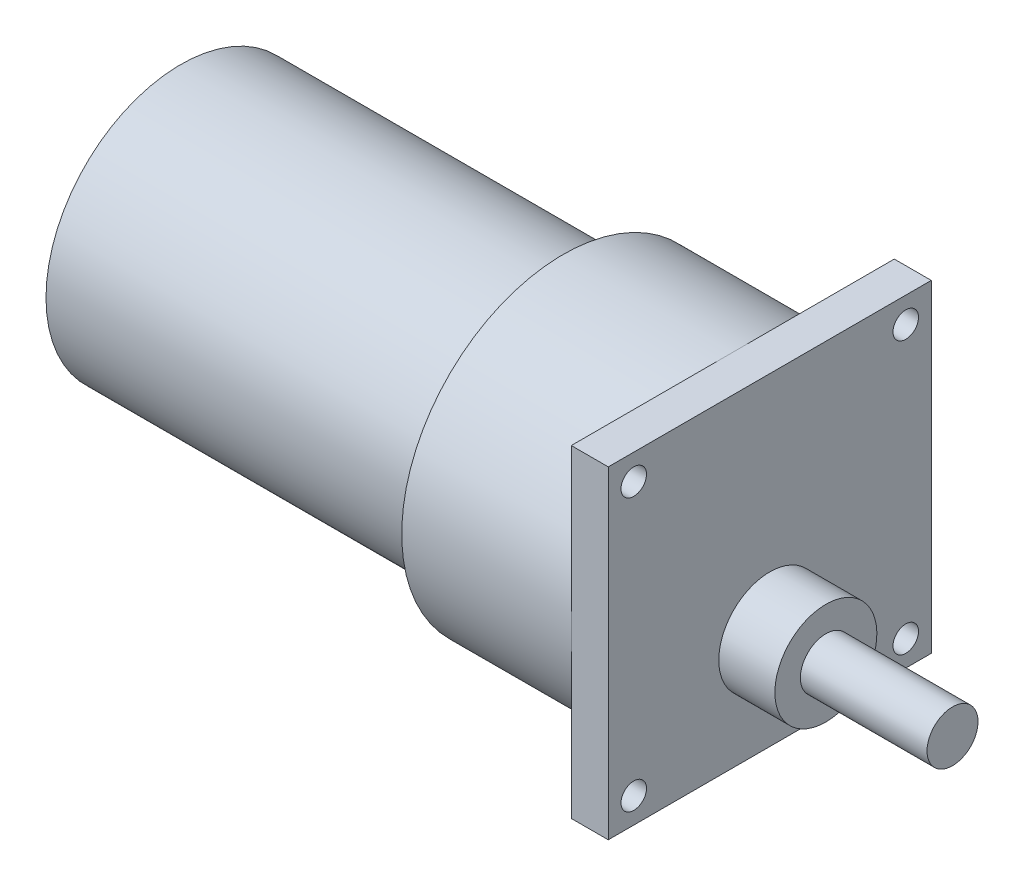
from build123d import *

# Parameters (mm, degrees)
BOSS_EXTRUDE1_DEPTH   = 24.3
BOSS_EXTRUDE2_DEPTH   = 4.35
SKETCH2_R             = 15.85
BOSS_EXTRUDE3_DEPTH   = 45
CORTE_EXTRUS_O1_REACH = 76.327
ESBO_O3_R             = 1.5


with BuildPart() as part:
    # Sketch1 → Boss-Extrude1 (new body)
    with BuildSketch(Plane(origin=(0, 0, 0), x_dir=(0, 0, -1), z_dir=(1, 0, 0))):
        with BuildLine():
            ThreePointArc((19, 0), (13.435028855, 13.43502883), (3.5e-08, 19))
            ThreePointArc((3.5e-08, 19), (-13.435028834, 13.435028851), (-19, -9e-09))
            ThreePointArc((-19, -9e-09), (-13.435028829, -13.435028856), (2.8e-08, -19))
            ThreePointArc((2.8e-08, -19), (13.435028852, -13.435028833), (19, 0))
        make_face()
    extrude(amount=-BOSS_EXTRUDE1_DEPTH)

    # Sketch1_3 → Boss-Extrude2 (add)
    with BuildSketch(Plane(origin=(0, 0, 0), x_dir=(0, 0, -1), z_dir=(1, 0, 0))):
        with BuildLine():
            Line((3.5e-08, 19), (-19, 19))
            Line((-19, 19), (-19, -9e-09))
            ThreePointArc((-19, -9e-09), (-13.435028834, 13.435028851), (3.5e-08, 19))
        make_face()
        with BuildLine():
            Line((19, 19), (3.5e-08, 19))
            ThreePointArc((3.5e-08, 19), (13.435028855, 13.43502883), (19, 0))
            Line((19, 0), (19, 19))
        make_face()
        with BuildLine():
            ThreePointArc((2.8e-08, -19), (-13.435028829, -13.435028856), (-19, -9e-09))
            Line((-19, -9e-09), (-19, -19))
            Line((-19, -19), (2.8e-08, -19))
        make_face()
        with BuildLine():
            Line((19, -19), (19, 0))
            ThreePointArc((19, 0), (13.435028852, -13.435028833), (2.8e-08, -19))
            Line((2.8e-08, -19), (19, -19))
        make_face()
    extrude(amount=-BOSS_EXTRUDE2_DEPTH)

    # Sketch2 → Boss-Extrude3 (add)
    with BuildSketch(Plane.ZY.offset(24.3)):
        Circle(SKETCH2_R)
    extrude(amount=BOSS_EXTRUDE3_DEPTH)

    # Esboço2 → Revolução1 (revolve)
    with BuildSketch(Plane.XY):
        Polygon((0, -1.2), (6.6, -1.2), (6.6, -4.2), (21.5, -4.2), (21.5, -7.2), (0, -7.2), align=None)
    revolve(axis=Axis((0, -7.2, 0), (1, 0, 0)))

    # Esboço3 → Corte-extrusão1 (cut, up to next)
    with BuildSketch(Plane(origin=(0, 0, 0), x_dir=(0, 0, -1), z_dir=(1, 0, 0)), mode=Mode.PRIVATE) as corte_extrus_o1_sk1:
        with Locations((-16, 16)):
            Circle(ESBO_O3_R)
    corte_extrus_o1_tool1 = extrude(corte_extrus_o1_sk1.sketch, amount=-CORTE_EXTRUS_O1_REACH, mode=Mode.PRIVATE) & part.part
    # Esboço3 → Corte-extrusão1 (cut, up to next)
    with BuildSketch(Plane(origin=(0, 0, 0), x_dir=(0, 0, -1), z_dir=(1, 0, 0)), mode=Mode.PRIVATE) as corte_extrus_o1_sk2:
        with Locations((16, 16)):
            Circle(ESBO_O3_R)
    corte_extrus_o1_tool2 = extrude(corte_extrus_o1_sk2.sketch, amount=-CORTE_EXTRUS_O1_REACH, mode=Mode.PRIVATE) & part.part
    # Esboço3 → Corte-extrusão1 (cut, up to next)
    with BuildSketch(Plane(origin=(0, 0, 0), x_dir=(0, 0, -1), z_dir=(1, 0, 0)), mode=Mode.PRIVATE) as corte_extrus_o1_sk3:
        with Locations((16, -16)):
            Circle(ESBO_O3_R)
    corte_extrus_o1_tool3 = extrude(corte_extrus_o1_sk3.sketch, amount=-CORTE_EXTRUS_O1_REACH, mode=Mode.PRIVATE) & part.part
    # Esboço3 → Corte-extrusão1 (cut, up to next)
    with BuildSketch(Plane(origin=(0, 0, 0), x_dir=(0, 0, -1), z_dir=(1, 0, 0)), mode=Mode.PRIVATE) as corte_extrus_o1_sk4:
        with Locations((-16, -16)):
            Circle(ESBO_O3_R)
    corte_extrus_o1_tool4 = extrude(corte_extrus_o1_sk4.sketch, amount=-CORTE_EXTRUS_O1_REACH, mode=Mode.PRIVATE) & part.part
    add(corte_extrus_o1_tool1.solids().sort_by_distance((0, 16, 16))[0], mode=Mode.SUBTRACT)
    add(corte_extrus_o1_tool2.solids().sort_by_distance((0, 16, -16))[0], mode=Mode.SUBTRACT)
    add(corte_extrus_o1_tool3.solids().sort_by_distance((0, -16, -16))[0], mode=Mode.SUBTRACT)
    add(corte_extrus_o1_tool4.solids().sort_by_distance((0, -16, 16))[0], mode=Mode.SUBTRACT)


solid = part.part
